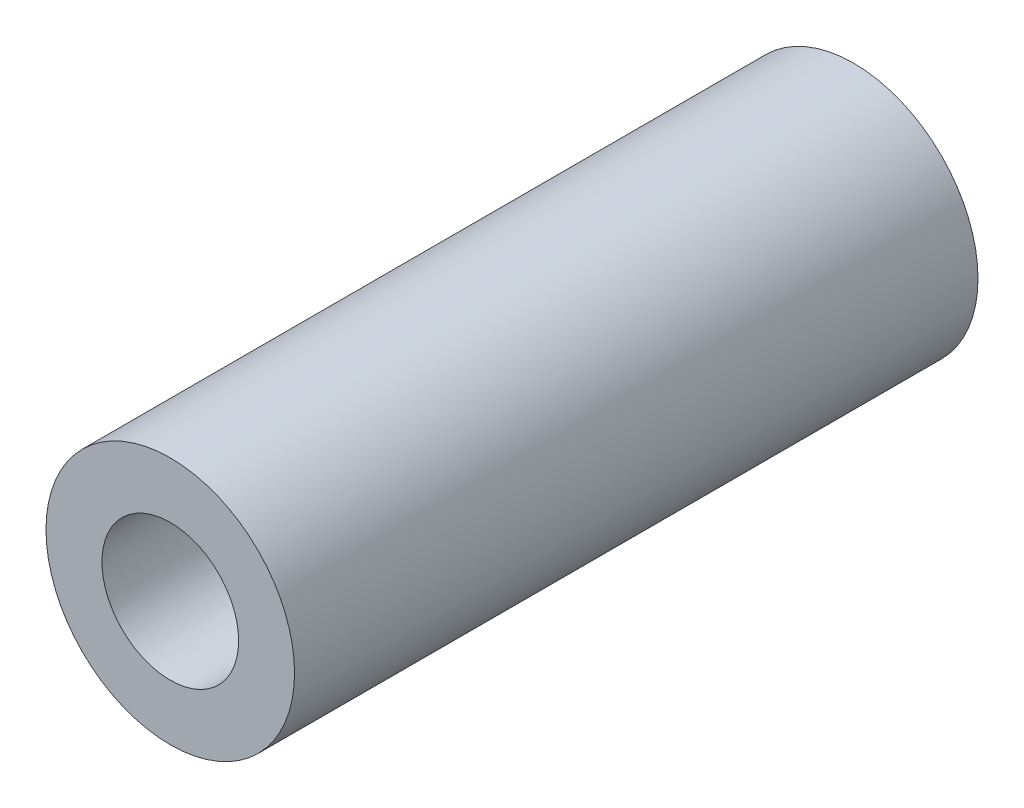
from build123d import *

# Parameters (mm, degrees)
SKETCH_1_R      = 2
SKETCH_1_R_2    = 1.1
EXTRUDE_1_DEPTH = 11


with BuildPart() as part:
    # 草图1 → 凸台-拉伸1 (new body)
    with BuildSketch(Plane.XY):
        Circle(SKETCH_1_R)
        Circle(SKETCH_1_R_2, mode=Mode.SUBTRACT)
    extrude(amount=EXTRUDE_1_DEPTH)


solid = part.part
